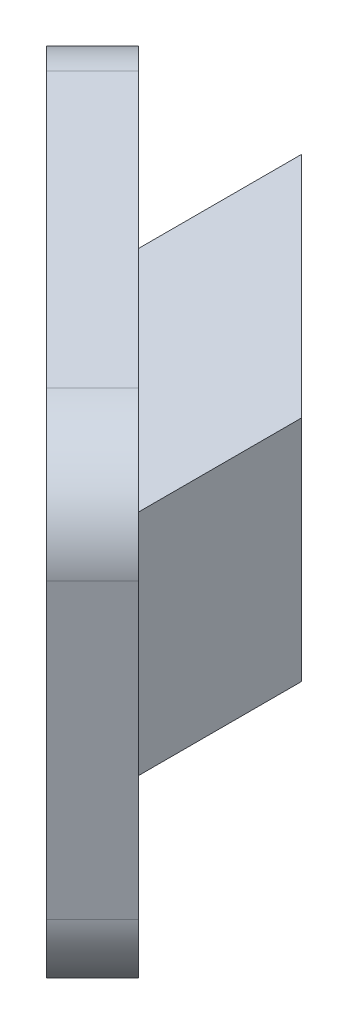
from build123d import *

# Parameters (mm, degrees)
SKETCH1_W           = 7
SKETCH1_H           = 7
SKETCH1_R           = 3
BOSS_EXTRUDE1_DEPTH = 12
CUT_EXTRUDE1_DEPTH  = 8
SKETCH5_W           = 17.899494936
SKETCH5_H           = 15
BOSS_EXTRUDE3_DEPTH = 2
SKETCH7_R           = 3
CUT_EXTRUDE3_DEPTH  = 17.242640687
CUT_EXTRUDE2_DEPTH  = 12
FILLET3_R           = 3


with BuildPart() as part:
    # Sketch1 → Boss-Extrude1 (new body)
    with BuildSketch(Plane.XY):
        Rectangle(SKETCH1_W, SKETCH1_H)
        Circle(SKETCH1_R, mode=Mode.SUBTRACT)
    extrude(amount=BOSS_EXTRUDE1_DEPTH)

    # Sketch3 → Cut-Extrude1 (cut, through all)
    with BuildSketch(Plane(origin=(0, 3.5, 0), x_dir=(1, 0, 0), z_dir=(0, 1, 0))):
        Polygon((-3.5, -12), (3.5, -12), (-3.5, -5), align=None)
    extrude(amount=-CUT_EXTRUDE1_DEPTH, mode=Mode.SUBTRACT)

    # Sketch5 → Boss-Extrude3 (add)
    with BuildSketch(Plane(origin=(-4.25, 0, 4.25), x_dir=(0.707106781, 0, 0.707106781), z_dir=(-0.707106781, 0, 0.707106781))):
        with Locations((6.01040764, 0)):
            Rectangle(SKETCH5_W, SKETCH5_H)
    extrude(amount=BOSS_EXTRUDE3_DEPTH)

    # Sketch7 → Cut-Extrude3 (cut, through all)
    with BuildSketch(Plane(origin=(0, 0, 0), x_dir=(-1, 0, 0), z_dir=(0, 0, -1))):
        Circle(SKETCH7_R)
    extrude(amount=-CUT_EXTRUDE3_DEPTH, mode=Mode.SUBTRACT)

    # Sketch6 → Cut-Extrude2 (cut, through all)
    with BuildSketch(Plane(origin=(0, 3.5, 0), x_dir=(1, 0, 0), z_dir=(0, 1, 0))):
        Polygon((-3.5, 0), (3.5, -7), (3.5, 0), align=None)
    extrude(amount=-CUT_EXTRUDE2_DEPTH, mode=Mode.SUBTRACT)

    # Fillet3
    fillet3_edges = [part.edges().sort_by_distance(p)[0] for p in [
        (5.621320344, -7.5, 15.535533906),
        (5.621320344, 7.5, 15.535533906),
        (-7.035533906, 7.5, 2.878679656),
        (-7.035533906, -7.5, 2.878679656),
    ]]
    fillet(fillet3_edges, radius=FILLET3_R)


solid = part.part
